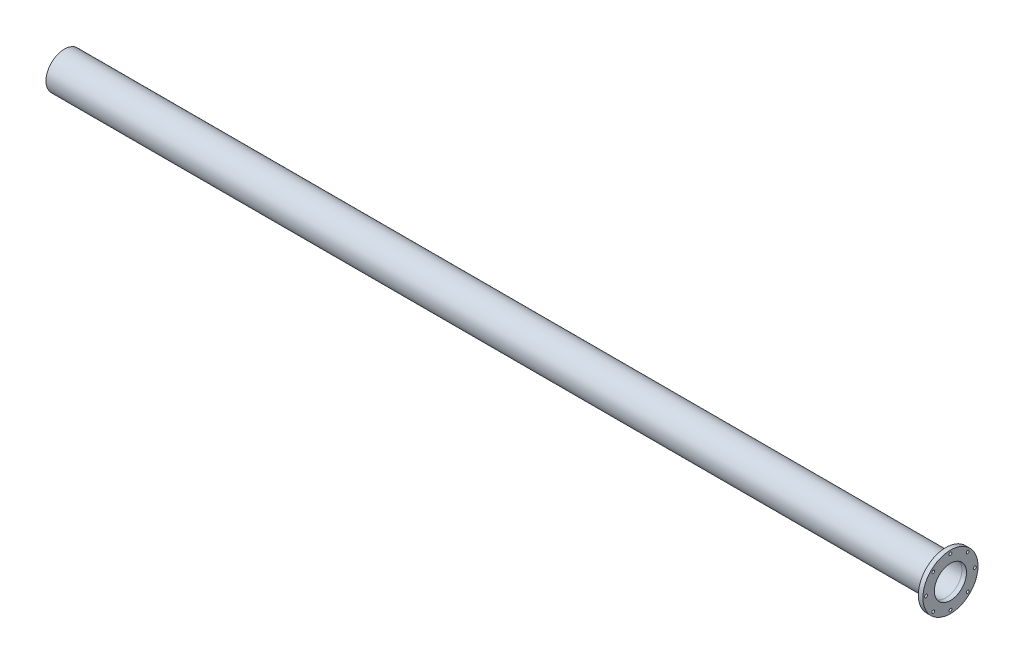
from build123d import *

# Parameters (mm, degrees)
BOSS_EXTRUDE1_DEPTH      = 1219.2
BOSS_EXTRUDE1_DEPTH_BACK = 1219.2
SKETCH1_R                = 50.8
SKETCH1_R_2              = 44.45
SKETCH2_R                = 76.2
SKETCH2_R_2              = 44.45
BOSS_EXTRUDE2_DEPTH      = 12.7
SKETCH3_R                = 3.96875
CUT_EXTRUDE1_DEPTH       = 12.7
CIRPATTERN1_COUNT        = 8


with BuildPart() as part:
    # Sketch1 → Boss-Extrude1 (new, two sides: drawn at the far end of the back side and taken through both)
    with BuildSketch(Plane(origin=(0, 0, 0), x_dir=(0, 0, -1), z_dir=(1, 0, 0)).offset(-BOSS_EXTRUDE1_DEPTH_BACK)):
        Circle(SKETCH1_R)
        Circle(SKETCH1_R_2, mode=Mode.SUBTRACT)
    extrude(amount=BOSS_EXTRUDE1_DEPTH + BOSS_EXTRUDE1_DEPTH_BACK)


with BuildPart() as body_2:
    # Sketch2 → Boss-Extrude2 (new body)
    with BuildSketch(Plane(origin=(1219.2, 0, 0), x_dir=(0, 0, -1), z_dir=(1, 0, 0))):
        Circle(SKETCH2_R)
        Circle(SKETCH2_R_2, mode=Mode.SUBTRACT)
    extrude(amount=BOSS_EXTRUDE2_DEPTH)

    # Sketch3 → Cut-Extrude1 (cut)
    with BuildSketch(Plane(origin=(1231.9, 0, 0), x_dir=(0, 0, -1), z_dir=(1, 0, 0))):
        with Locations((67.46875, 0)):
            Circle(SKETCH3_R)
    cut_extrude1 = extrude(amount=-CUT_EXTRUDE1_DEPTH, mode=Mode.SUBTRACT)

    # CirPattern1: Cut-Extrude1 ×8 about axis
    cirpattern1_axis = Axis((1231.9, 0, 0), (1, 0, 0))
    for i in range(1, CIRPATTERN1_COUNT):
        add(cut_extrude1.rotate(cirpattern1_axis, i * 360 / CIRPATTERN1_COUNT), mode=Mode.SUBTRACT)


solid = Compound([part.part, body_2.part])
